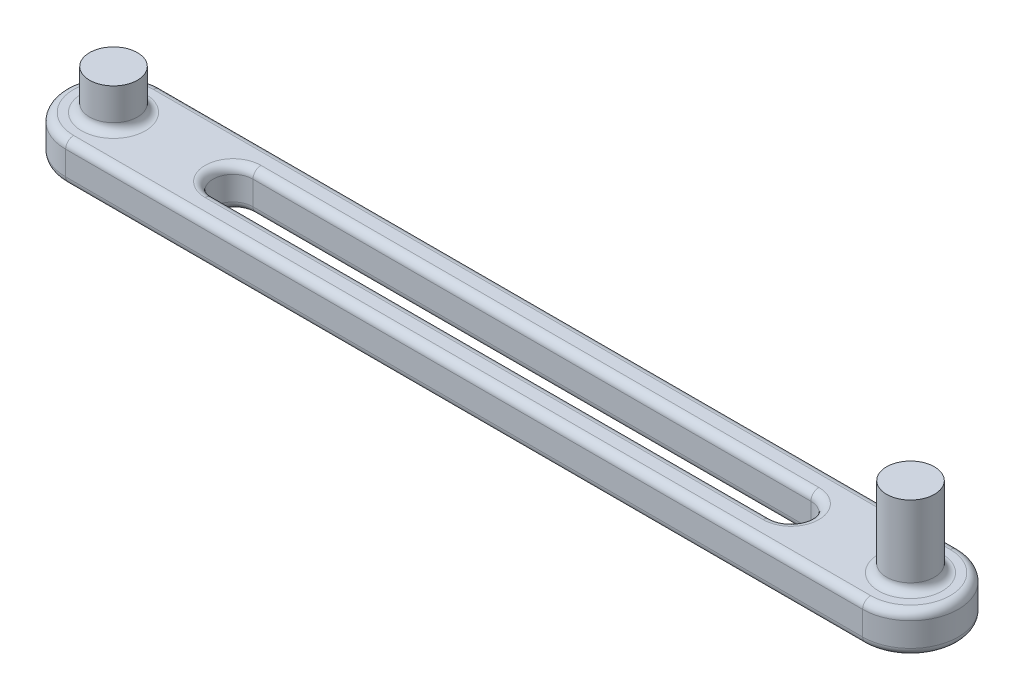
from build123d import *

# Parameters (mm, degrees)
SKETCH_1_R          = 6
EXTRUDE_1_DEPTH     = 5
EXTRUDE_1_2_DEPTH   = 5
SKETCH_3_W          = 100
SKETCH_3_H          = 12
EXTRUDE_3_DEPTH     = 5
SKETCH_6_R          = 2.5
CUT_EXTRUDE_3_DEPTH = 6
SKETCH_7_W          = 70
SKETCH_7_H          = 5
CUT_EXTRUDE_4_DEPTH = 6
SKETCH_4_R          = 3
EXTRUDE_4_DEPTH     = 5
SKETCH_5_R          = 3
EXTRUDE_5_DEPTH     = 10
FILLET_1_R          = 1
FILLET_2_R          = 1


with BuildPart() as part:
    # 草图1 → 凸台-拉伸1 (new body)
    with BuildSketch(Plane(origin=(0, 0, 0), x_dir=(1, 0, 0), z_dir=(0, 1, 0))):
        with Locations((-50, 0)):
            Circle(SKETCH_1_R)
    extrude(amount=EXTRUDE_1_DEPTH)



with BuildPart() as body_2:
    # 草图1 → Extrude 1 2 (new body)
    with BuildSketch(Plane(origin=(0, 0, 0), x_dir=(1, 0, 0), z_dir=(0, 1, 0))):
        with Locations((50, 0)):
            Circle(SKETCH_1_R)
    extrude(amount=EXTRUDE_1_2_DEPTH)


with BuildPart() as part_1:
    add(part.part)

    add(body_2.part)  # 凸台-拉伸3 merges body 2
    # 草图3 → 凸台-拉伸3 (add)
    with BuildSketch(Plane(origin=(0, 0, 0), x_dir=(1, 0, 0), z_dir=(0, 1, 0))):
        Rectangle(SKETCH_3_W, SKETCH_3_H)
    extrude(amount=EXTRUDE_3_DEPTH)

    # 草图6 → 切除-拉伸3 (cut, through all)
    with BuildSketch(Plane(origin=(0, 5, 0), x_dir=(1, 0, 0), z_dir=(0, 1, 0))):
        with Locations((-35, 0)):
            Circle(SKETCH_6_R)
        with Locations((35, 0)):
            Circle(SKETCH_6_R)
    extrude(amount=-CUT_EXTRUDE_3_DEPTH, mode=Mode.SUBTRACT)

    # 草图7 → 切除-拉伸4 (cut, through all)
    with BuildSketch(Plane(origin=(0, 5, 0), x_dir=(1, 0, 0), z_dir=(0, 1, 0))):
        Rectangle(SKETCH_7_W, SKETCH_7_H)
    extrude(amount=-CUT_EXTRUDE_4_DEPTH, mode=Mode.SUBTRACT)

    # 草图4 → 凸台-拉伸4 (add)
    with BuildSketch(Plane(origin=(0, 5, 0), x_dir=(1, 0, 0), z_dir=(0, 1, 0))):
        with Locations((-50, 0)):
            Circle(SKETCH_4_R)
    extrude(amount=EXTRUDE_4_DEPTH)

    # 草图5 → 凸台-拉伸5 (add)
    with BuildSketch(Plane(origin=(0, 5, 0), x_dir=(1, 0, 0), z_dir=(0, 1, 0))):
        with Locations((50, 0)):
            Circle(SKETCH_5_R)
    extrude(amount=EXTRUDE_5_DEPTH)

    # 圆角1
    fillet_1_edges = [part_1.edges().sort_by_distance(p)[0] for p in [
        (-53, 5, 0),
        (47, 5, 0),
    ]]
    fillet(fillet_1_edges, radius=FILLET_1_R)

    # 圆角2
    fillet_2_edges = [part_1.edges().sort_by_distance(p)[0] for p in [
        (0, 5, 6),
        (56, 0, 0),
        (56, 5, 0),
        (37.5, 0, 0),
        (37.5, 5, 0),
        (-37.5, 0, 0),
        (-37.5, 5, 0),
        (0, 5, -2.5),
        (0, 5, 2.5),
        (0, 0, -2.5),
        (0, 0, 2.5),
        (-56, 0, 0),
        (-56, 5, 0),
        (0, 0, 6),
        (0, 0, -6),
        (0, 5, -6),
    ]]
    fillet(fillet_2_edges, radius=FILLET_2_R)


solid = part_1.part
